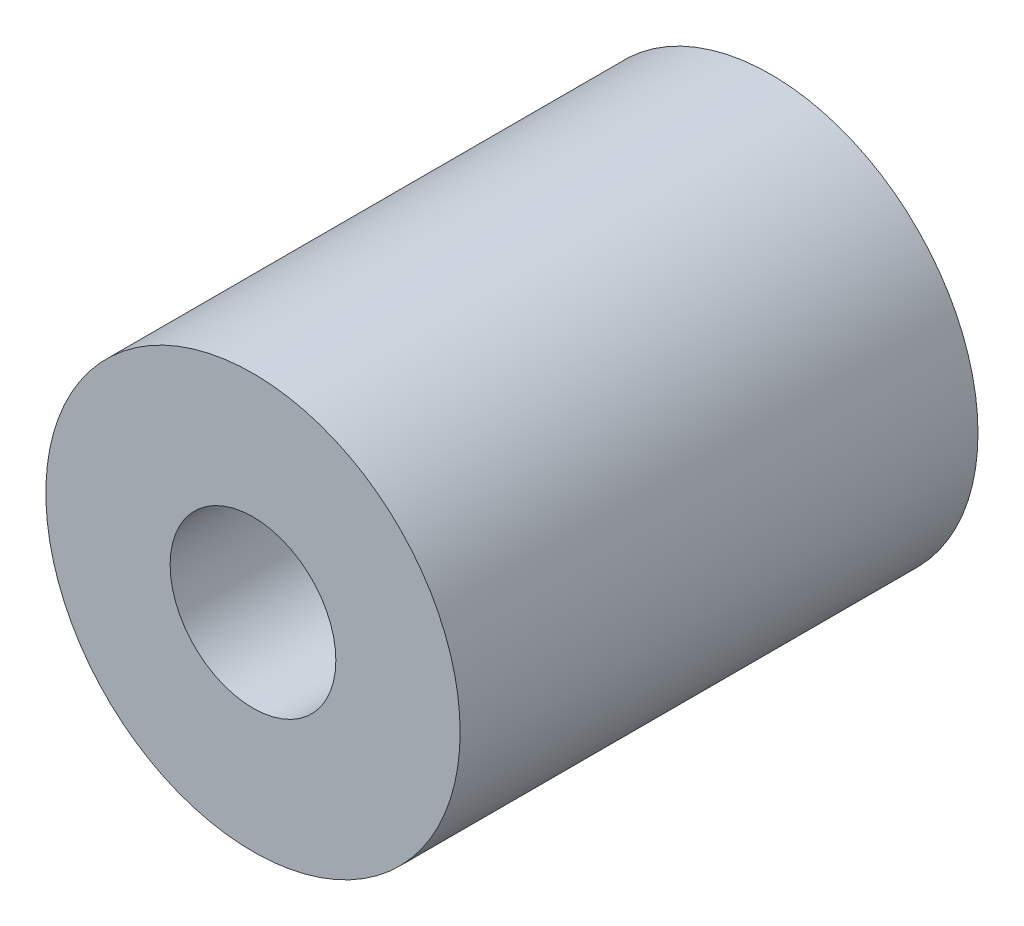
from build123d import *

# Parameters (mm, degrees)
SKIZZE1_R                       = 10
SKIZZE1_R_2                     = 4
AUFSATZ_LINEAR_AUSTRAGEN1_DEPTH = 25


with BuildPart() as part:
    # Skizze1 → Aufsatz-Linear austragen1 (new body)
    with BuildSketch(Plane.XY):
        Circle(SKIZZE1_R)
        Circle(SKIZZE1_R_2, mode=Mode.SUBTRACT)
    extrude(amount=AUFSATZ_LINEAR_AUSTRAGEN1_DEPTH)


solid = part.part
